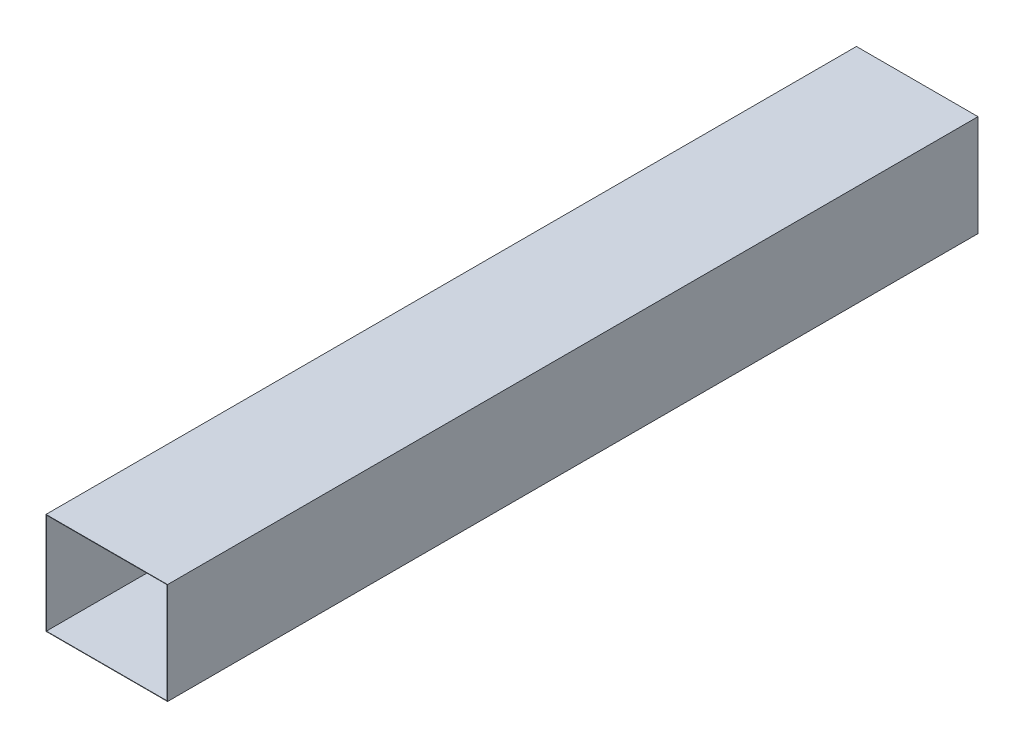
from build123d import *

# Parameters (mm, degrees)
SKETCH1_W           = 300
SKETCH1_H           = 250
SKETCH1_W_2         = 298
SKETCH1_H_2         = 248
EXTRUDE_THIN1_DEPTH = 2000


with BuildPart() as part:
    # Sketch1 → Extrude-Thin1 (new body)
    with BuildSketch(Plane.XY):
        with Locations((-150, 125)):
            Rectangle(SKETCH1_W, SKETCH1_H)
        with Locations((-150, 125)):
            Rectangle(SKETCH1_W_2, SKETCH1_H_2, mode=Mode.SUBTRACT)
    extrude(amount=EXTRUDE_THIN1_DEPTH)


solid = part.part
